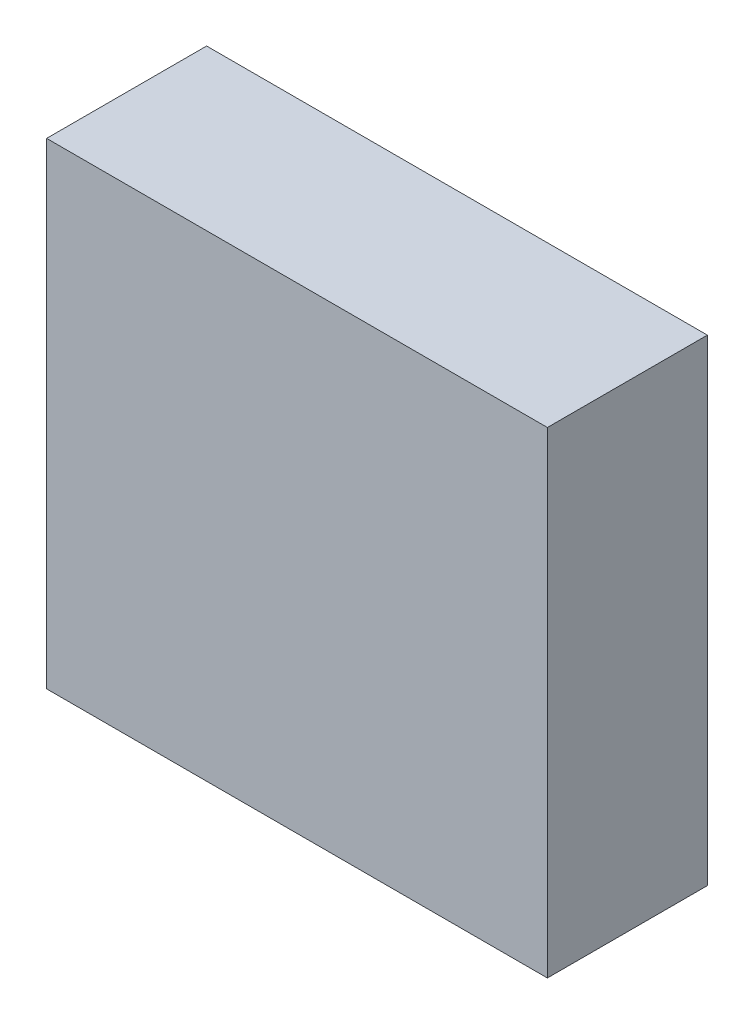
from build123d import *

# Parameters (mm, degrees)
SKETCH1_W           = 79.502
SKETCH1_H           = 75.692
BOSS_EXTRUDE1_DEPTH = 25.4


with BuildPart() as part:
    # Sketch1 → Boss-Extrude1 (new body)
    with BuildSketch(Plane.XY):
        Rectangle(SKETCH1_W, SKETCH1_H)
    extrude(amount=BOSS_EXTRUDE1_DEPTH)


solid = part.part
